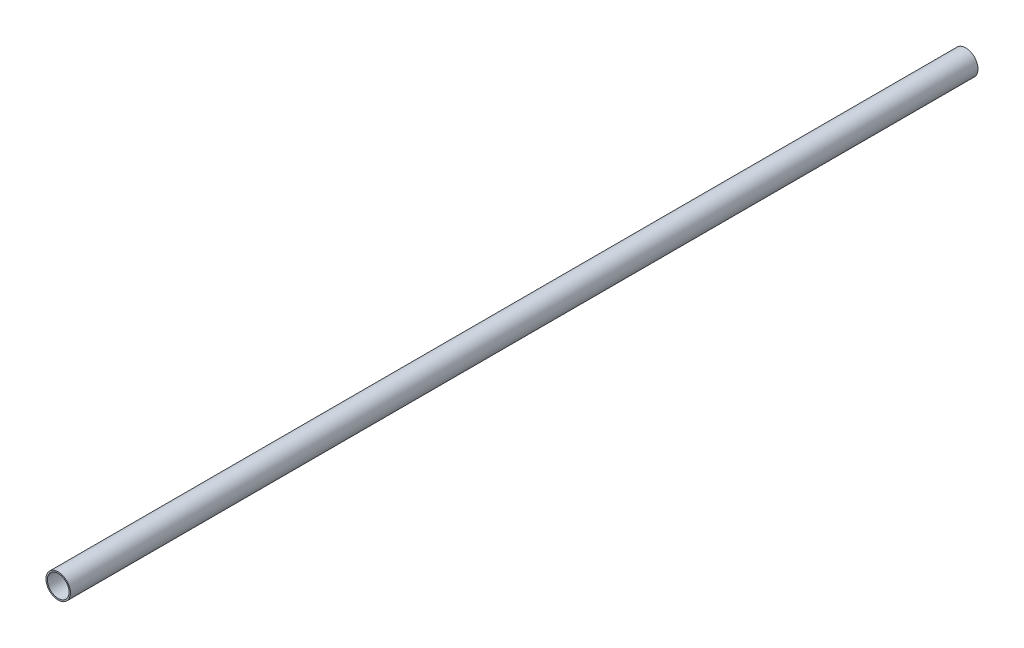
from build123d import *

# Parameters (mm, degrees)
SKETCH1_R           = 16.59255
SKETCH1_R_2         = 14.72565
BOSS_EXTRUDE1_DEPTH = 1231.9


with BuildPart() as part:
    # Sketch1 → Boss-Extrude1 (new body)
    with BuildSketch(Plane.XY):
        Circle(SKETCH1_R)
        Circle(SKETCH1_R_2, mode=Mode.SUBTRACT)
    extrude(amount=BOSS_EXTRUDE1_DEPTH)


solid = part.part
